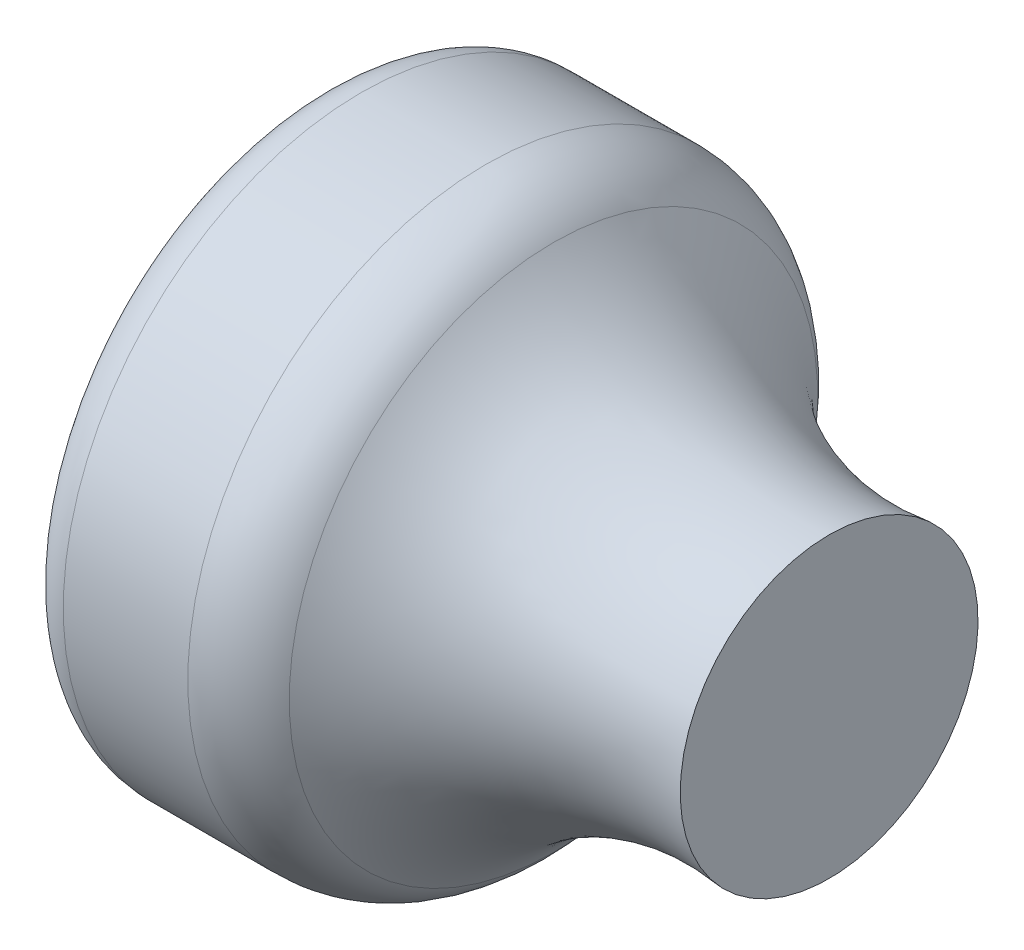
from build123d import *


with BuildPart() as part:
    # Sketch1 → Revolve1 (revolve)
    with BuildSketch(Plane.XY):
        with BuildLine():
            Line((-12, 0), (-12, 6))
            ThreePointArc((-12, 6), (-11.707106781, 6.707106781), (-11, 7))
            Line((-11, 7), (-8.073140091, 7))
            ThreePointArc((-8.073140091, 7), (-7.183863099, 6.791420227), (-6.4800713, 6.209186431))
            ThreePointArc((-6.4800713, 6.209186431), (-3.60441223, 3.983045141), (0, 3.5))
            Line((0, 3.5), (0, 0))
            Line((0, 0), (-12, 0))
        make_face()
    revolve(axis=Axis((0, 0, 0), (-1, 0, 0)))


solid = part.part
